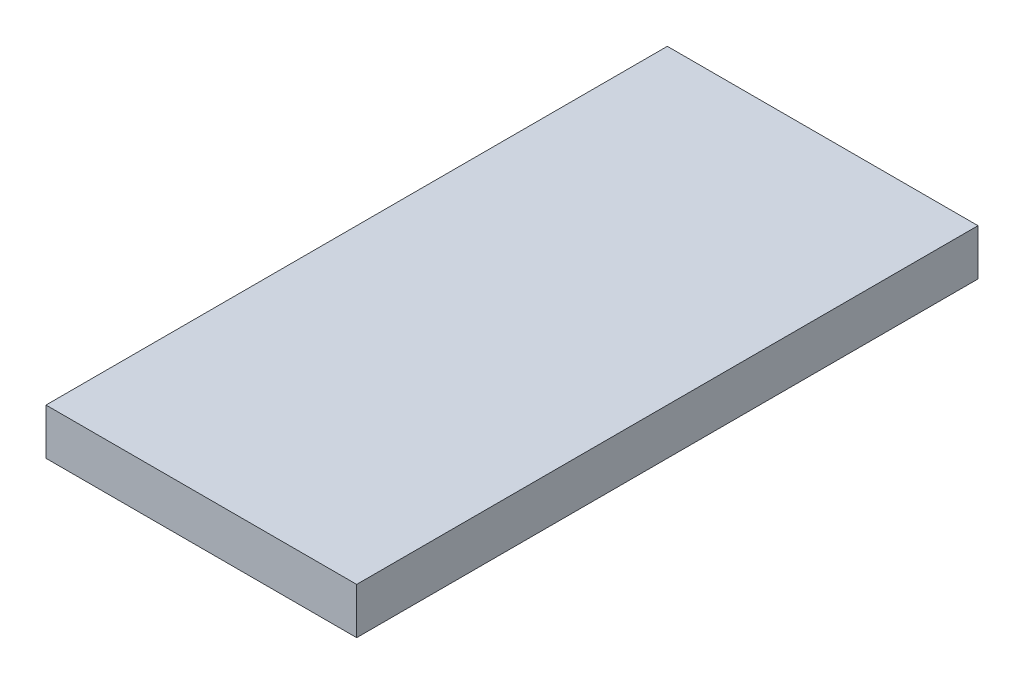
from build123d import *

# Parameters (mm, degrees)
L_U_BR_W             = 100
L_U_BR_H             = 200
AUFSATZ_LIN_GK_DEPTH = 14.86


with BuildPart() as part:
    # L_ u Br → Aufsatz-Lin_GK (new body)
    with BuildSketch(Plane(origin=(0, 0, 0), x_dir=(1, 0, 0), z_dir=(0, 1, 0))):
        with Locations((50, -100)):
            Rectangle(L_U_BR_W, L_U_BR_H)
    extrude(amount=AUFSATZ_LIN_GK_DEPTH)


solid = part.part
